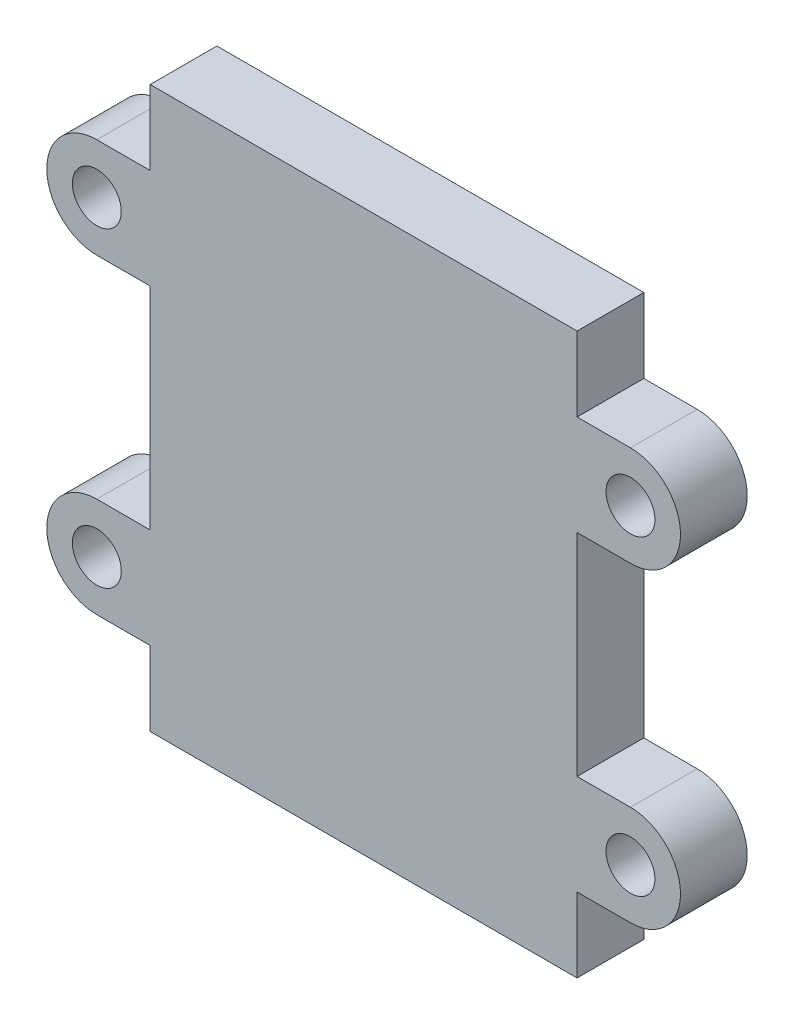
from build123d import *

# Parameters (mm, degrees)
SKETCH_1_W          = 19.2
SKETCH_1_H          = 25.2
EXTRUDE_1_DEPTH     = 3
SKETCH_3_R          = 1.1
EXTRUDE_2_DEPTH     = 3
SKETCH_4_R          = 1.15
CUT_EXTRUDE_1_DEPTH = 7
SKETCH_5_R          = 2.5
EXTRUDE_3_DEPTH     = 3


with BuildPart() as part:
    # 草图1 → 凸台-拉伸1 (new body)
    with BuildSketch(Plane.XY):
        Rectangle(SKETCH_1_W, SKETCH_1_H)
    extrude(amount=EXTRUDE_1_DEPTH)

    # 草图3 → 凸台-拉伸2 (add, through all)
    with BuildSketch(Plane.XY.offset(3)):
        with BuildLine():
            Line((12, 9.25), (9.6, 9.25))
            Line((9.6, 9.25), (9.6, 4.75))
            Line((9.6, 4.75), (12, 4.75))
            ThreePointArc((12, 4.75), (14.25, 7), (12, 9.25))
        make_face()
        with Locations((12, 7)):
            Circle(SKETCH_3_R, mode=Mode.SUBTRACT)
        with BuildLine():
            Line((9.6, -9.25), (9.6, -4.75))
            Line((9.6, -4.75), (12, -4.75))
            ThreePointArc((12, -4.75), (14.25, -7), (12, -9.25))
            Line((12, -9.25), (9.6, -9.25))
        make_face()
        with Locations((12, -7)):
            Circle(SKETCH_3_R, mode=Mode.SUBTRACT)
        with BuildLine():
            Line((-12, -9.25), (-9.6, -9.25))
            Line((-9.6, -9.25), (-9.6, -4.75))
            Line((-9.6, -4.75), (-12, -4.75))
            ThreePointArc((-12, -4.75), (-14.25, -7), (-12, -9.25))
        make_face()
        with Locations((-12, -7)):
            Circle(SKETCH_3_R, mode=Mode.SUBTRACT)
        with BuildLine():
            Line((-9.6, 9.25), (-9.6, 4.75))
            Line((-9.6, 4.75), (-12, 4.75))
            ThreePointArc((-12, 4.75), (-14.25, 7), (-12, 9.25))
            Line((-12, 9.25), (-9.6, 9.25))
        make_face()
        with Locations((-12, 7)):
            Circle(SKETCH_3_R, mode=Mode.SUBTRACT)
    extrude_2 = extrude(amount=-EXTRUDE_2_DEPTH)

    # 镜向1: 凸台-拉伸2 across plane
    add(extrude_2.mirror(Plane.ZX))

    # 草图4 → 切除-拉伸1 (cut)
    with BuildSketch(Plane(origin=(-9.6, 3, 0), x_dir=(0, 1, 0), z_dir=(-1, 0, 0))):
        with Locations((-3, 0)):
            Circle(SKETCH_4_R)
    extrude(amount=-CUT_EXTRUDE_1_DEPTH, mode=Mode.SUBTRACT)

    # 草图5 → 凸台-拉伸3 (add)
    with BuildSketch(Plane(origin=(0, 0, 0), x_dir=(-1, 0, 0), z_dir=(0, 0, -1))):
        Circle(SKETCH_5_R)
    extrude(amount=EXTRUDE_3_DEPTH)


solid = part.part
